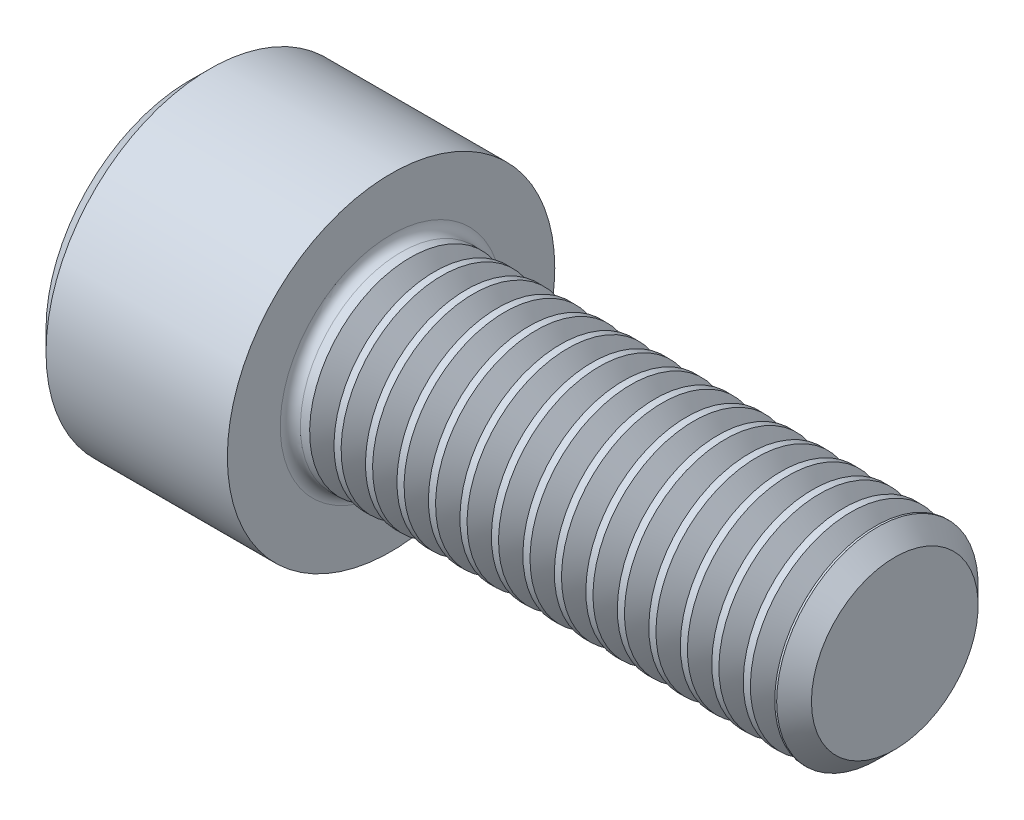
from build123d import *

# Parameters (mm, degrees)
FILLET1_R       = 0.4
HEX_2_DEPTH     = 4
THDSCHPAT_COUNT = 15
THDSCHPAT_PITCH = 1.25


with BuildPart() as part:
    # BodySke → Base-Revolve (revolve)
    with BuildSketch(Plane.XY):
        Polygon((0, 0), (0, 5.7), (0.8, 6.5), (8, 6.5), (8, 4), (27.3095, 4), (28, 3.3095), (28, 0), align=None)
    revolve(axis=Axis((-31.75, 0, 0), (1, 0, 0)))

    # Fillet1
    fillet1_edges = [part.edges().sort_by_distance(p)[0] for p in [
        (8, -4, 0),
    ]]
    fillet(fillet1_edges, radius=FILLET1_R)

    # Sketch2 → Hex-PreBroach (revolve, cut)
    with BuildSketch(Plane.XY):
        Polygon((0, 3.0475), (4, 3.0475), (5.759474945, 0), (0, 0), align=None)
    revolve(axis=Axis((0, 0, 0), (1, 0, 0)), mode=Mode.SUBTRACT)

    # Sketch3 → Hex 2 (cut)
    with BuildSketch(Plane(origin=(0, 0, 0), x_dir=(0, 0.5, 0.866025404), z_dir=(-1, 0, 0))):
        Polygon((1.759474945, 3.0475), (-1.759474945, 3.0475), (-3.518949891, 0), (-1.759474945, -3.0475), (1.759474945, -3.0475), (3.518949891, 0), align=None)
    extrude(amount=-HEX_2_DEPTH, mode=Mode.SUBTRACT)

    # ThdSchSke → ThreadSchematic (revolve, cut)
    with BuildSketch(Plane.XY):
        Polygon((9.25, -3.3095), (8.766506695, -4), (8.766506695, -5), (9.733493305, -5), (9.733493305, -4), align=None)
    threadschematic = revolve(axis=Axis((-3.175, 0, 0), (1, 0, 0)), mode=Mode.SUBTRACT)

    # ThdSchPat: ThreadSchematic ×15
    with Locations(*[(i * THDSCHPAT_PITCH, 0, 0) for i in range(1, THDSCHPAT_COUNT)]):
        add(threadschematic, mode=Mode.SUBTRACT)


solid = part.part
